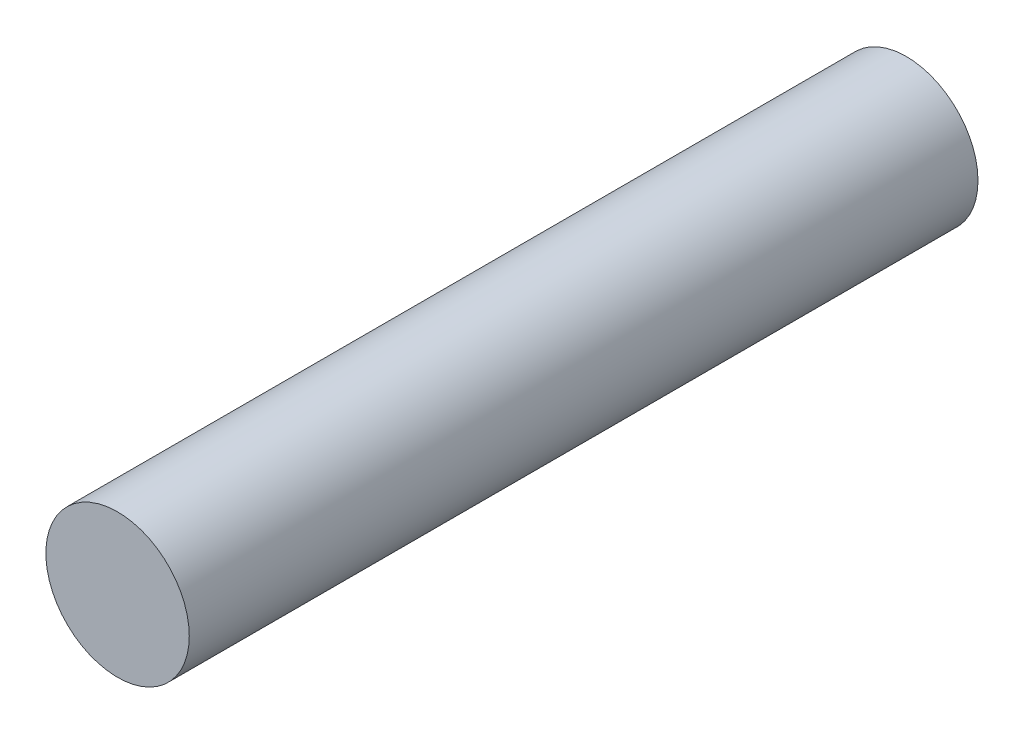
from build123d import *

# Parameters (mm, degrees)
CROQUIS1_R              = 0.25
SALIENTE_EXTRUIR1_DEPTH = 2.75


with BuildPart() as part:
    # Croquis1 → Saliente-Extruir1 (new body)
    with BuildSketch(Plane.XY):
        Circle(CROQUIS1_R)
    extrude(amount=SALIENTE_EXTRUIR1_DEPTH)


solid = part.part
